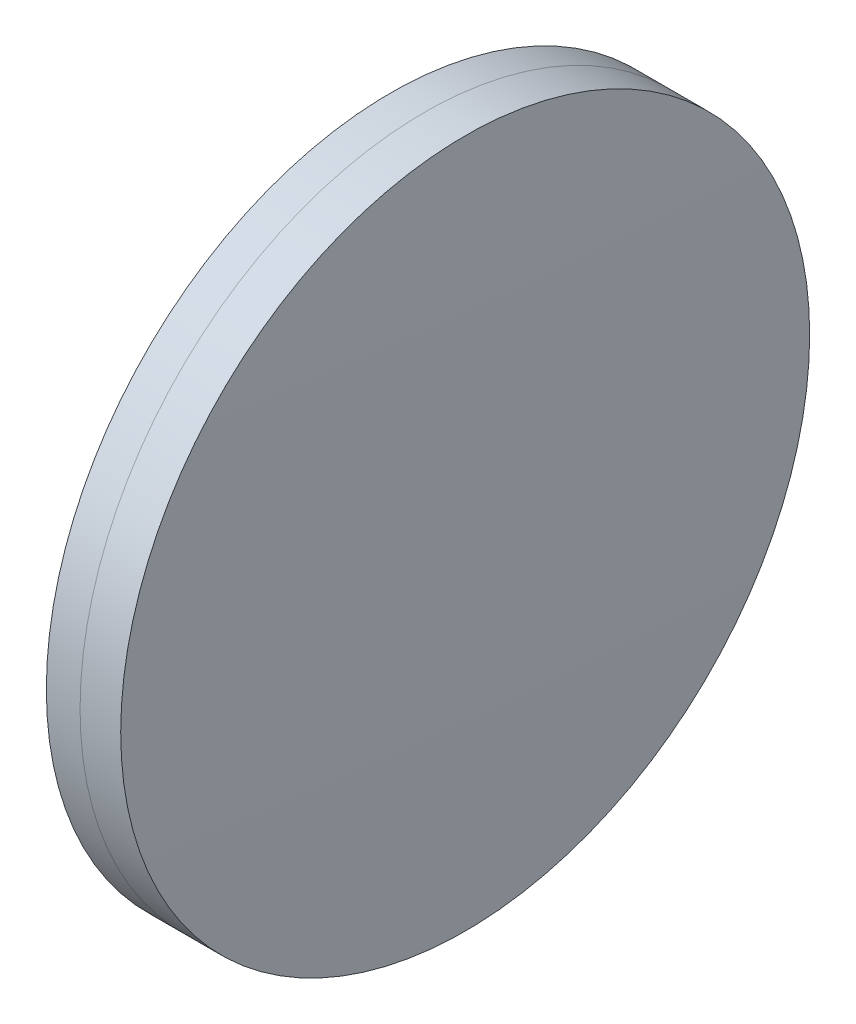
from build123d import *


with BuildPart() as part:
    # 草图1 one side → 旋转1 (revolve)
    with BuildSketch(Plane(origin=(0, 0, 0), x_dir=(1, 0, 0), z_dir=(0, 1, 0)), mode=Mode.PRIVATE) as revolve_1_sk:
        with BuildLine():
            ThreePointArc((497.106398263, 25.4), (496.218097267, 12.713804649), (495.921782443, 0))
            Line((495.921782443, 0), (500.921782443, 0))
            ThreePointArc((500.921782443, 0), (500.58918379, 12.71738506), (499.592297176, 25.4))
            Line((499.592297176, 25.4), (497.106398263, 25.4))
        make_face()
    revolve(revolve_1_sk.sketch.rotate(Axis((124.523309526, 0, 0), (1, 0, 0)), 180), axis=Axis((124.523309526, 0, 0), (1, 0, 0)))  # turned: the seam where the file's is


with BuildPart() as body_2:
    # 草图2 one side → 旋转3 (revolve)
    with BuildSketch(Plane(origin=(0, 0, 0), x_dir=(1, 0, 0), z_dir=(0, 1, 0)), mode=Mode.PRIVATE) as revolve_3_sk:
        with BuildLine():
            Line((502.589168715, 25.4), (499.592297176, 25.4))
            ThreePointArc((499.592297176, 25.4), (500.58918379, 12.71738506), (500.921782443, 0))
            Line((500.921782443, 0), (502.921782443, 0))
            ThreePointArc((502.921782443, 0), (502.838625447, 12.70108885), (502.589168715, 25.4))
        make_face()
    revolve(revolve_3_sk.sketch.rotate(Axis((-0.551919993, 0, 0), (1, 0, 0)), 180), axis=Axis((-0.551919993, 0, 0), (1, 0, 0)))  # turned: the seam where the file's is


solid = Compound([part.part, body_2.part])
